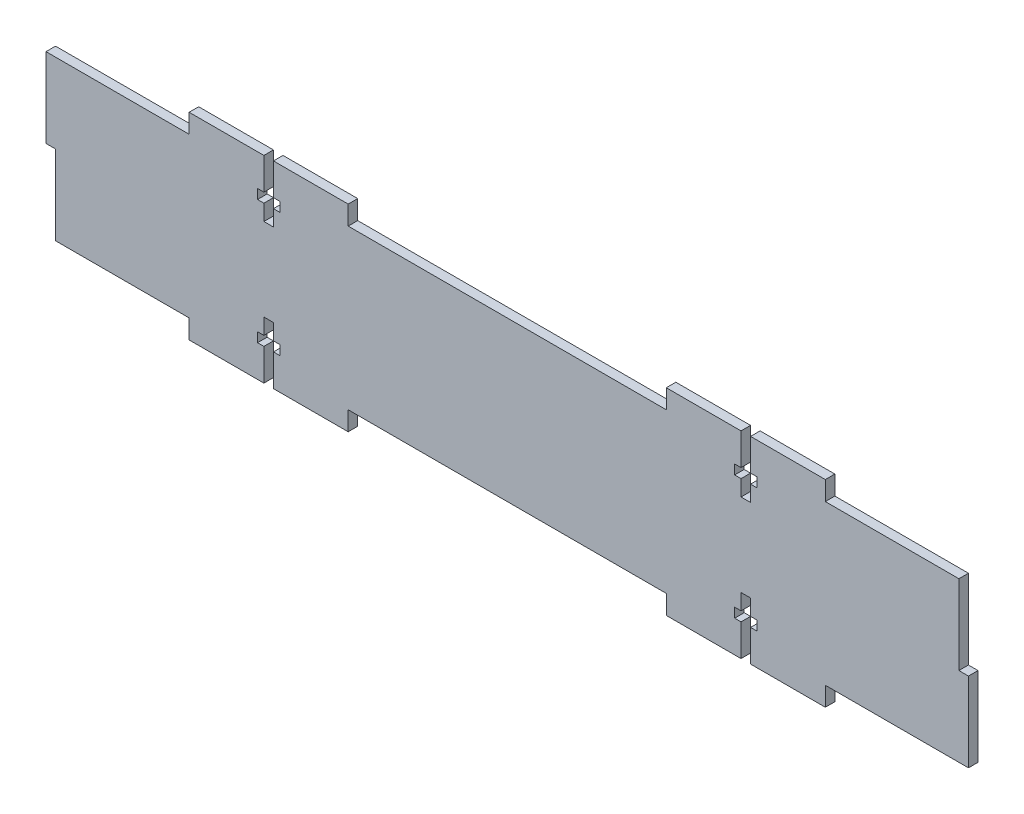
from build123d import *

# Parameters (mm, degrees)
BOSS_EXTRUDE1_DEPTH = 3
CUT_EXTRUDE1_DEPTH  = 10


with BuildPart() as part:
    # Sketch1 → Boss-Extrude1 (new body)
    with BuildSketch(Plane.XY):
        Polygon((-145, 0), (-142, 0), (-142, -25), (-100, -25), (-100, -31), (-50, -31), (-50, -25), (50, -25), (50, -31), (100, -31), (100, -25), (145, -25), (145, 0), (142, 0), (142, 25), (100, 25), (100, 31), (50, 31), (50, 25), (-50, 25), (-50, 31), (-100, 31), (-100, 25), (-145, 25), align=None)
    extrude(amount=BOSS_EXTRUDE1_DEPTH)

    # Sketch2 → Cut-Extrude1 (cut)
    with BuildSketch(Plane.XY.offset(3)):
        Polygon((-75, 31), (-76.5, 31), (-76.5, 21), (-78.5, 21), (-78.5, 18), (-76.5, 18), (-76.5, 13), (-73.5, 13), (-73.5, 18), (-71.5, 18), (-71.5, 21), (-73.5, 21), (-73.5, 31), align=None)
        Polygon((-76.5, -31), (-76.5, -21), (-78.5, -21), (-78.5, -18), (-76.5, -18), (-76.5, -13), (-73.5, -13), (-73.5, -18), (-71.5, -18), (-71.5, -21), (-73.5, -21), (-73.5, -31), align=None)
        Polygon((73.5, 31), (73.5, 21), (71.5, 21), (71.5, 18), (73.5, 18), (73.5, 13), (76.5, 13), (76.5, 18), (78.5, 18), (78.5, 21), (76.5, 21), (76.5, 31), align=None)
        Polygon((73.5, -31), (73.5, -21), (71.5, -21), (71.5, -18), (73.5, -18), (73.5, -13), (76.5, -13), (76.5, -18), (78.5, -18), (78.5, -21), (76.5, -21), (76.5, -31), align=None)
    extrude(amount=-CUT_EXTRUDE1_DEPTH, mode=Mode.SUBTRACT)


solid = part.part
